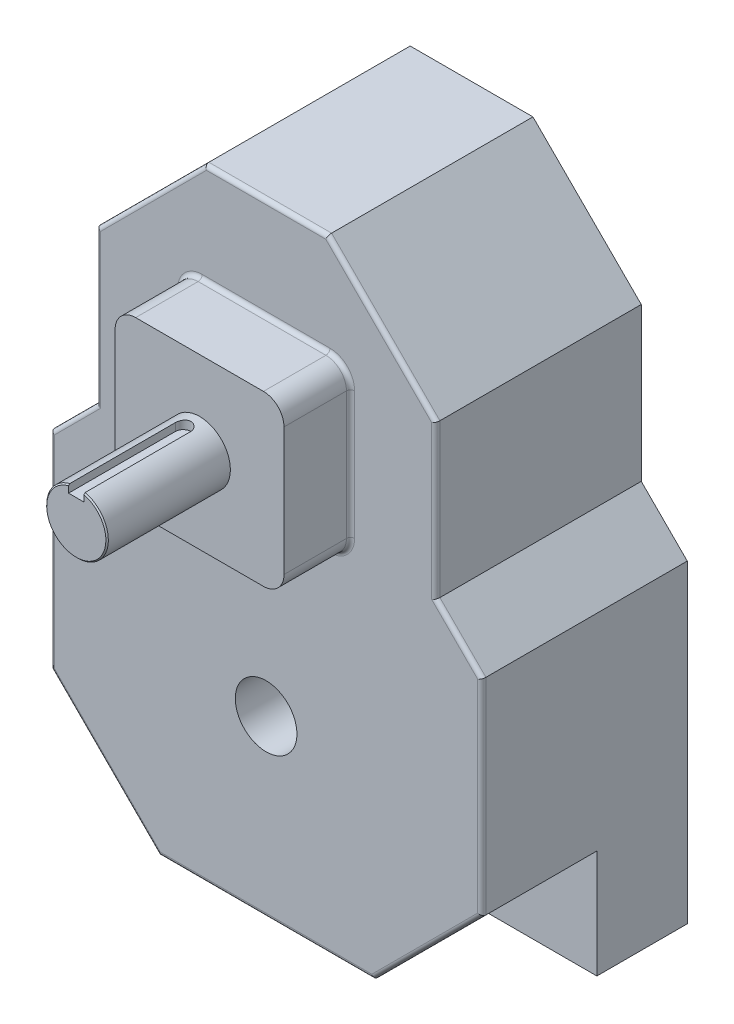
from build123d import *

# Parameters (mm, degrees)
BOSS_EXTRUDE1_DEPTH = 63.5
SKETCH3_W           = 52.197
SKETCH3_H           = 52.197
BOSS_EXTRUDE2_DEPTH = 20.574
SKETCH_D_R          = 9.525
BOSS_EXTRUDE3_DEPTH = 38.1
CUT_EXTRUDE1_DEPTH  = 35.56
FILLET1_R           = 6.35
FILLET2_R           = 1.27
KEYWAY_START        = 6.8326
KEYWAY_DEPTH        = 51.3174
CHAMFER1_SIZE       = 0.381
SKETCH7_R           = 9.525
CUT_EXTRUDE3_DEPTH  = 123.174


with BuildPart() as part:
    # L,M → Boss-Extrude1 (new body)
    with BuildSketch(Plane.XY):
        Polygon((-66.675, 53.975), (66.675, 53.975), (66.675, 151.07969491), (52.451, 165.30369491), (52.451, 212.64830509), (18.97330509, 246.126), (-18.97330509, 246.126), (-52.451, 212.64830509), (-52.451, 165.30369491), (-66.675, 151.07969491), align=None)
    extrude(amount=BOSS_EXTRUDE1_DEPTH)

    # Sketch3 → Boss-Extrude2 (add)
    with BuildSketch(Plane.XY.offset(63.5)):
        with Locations((0, 188.976)):
            Rectangle(SKETCH3_W, SKETCH3_H)
    extrude(amount=BOSS_EXTRUDE2_DEPTH)

    # D → Boss-Extrude3 (add)
    with BuildSketch(Plane.XY.offset(84.074)):
        with Locations((0, 188.976)):
            Circle(SKETCH_D_R)
    extrude(amount=BOSS_EXTRUDE3_DEPTH)

    # Sketch5 → Cut-Extrude1 (cut)
    with BuildSketch(Plane.XY.offset(63.5)):
        Polygon((66.675, 87.45269491), (33.19730509, 53.975), (66.675, 53.975), align=None)
        Polygon((-66.675, 53.975), (-66.675, 87.45269491), (-33.19730509, 53.975), align=None)
    extrude(amount=-CUT_EXTRUDE1_DEPTH, mode=Mode.SUBTRACT)

    # Fillet1
    fillet1_edges = [part.edges().sort_by_distance(p)[0] for p in [
        (-26.0985, 215.0745, 73.787),
        (-26.0985, 162.8775, 73.787),
        (26.0985, 162.8775, 73.787),
        (26.0985, 215.0745, 73.787),
    ]]
    fillet(fillet1_edges, radius=FILLET1_R)

    # Fillet2
    fillet2_edges = [part.edges().sort_by_distance(p)[0] for p in [
        (66.675, 119.26619491, 63.5),
        (49.936152545, 70.713847455, 63.5),
        (59.563, 158.19169491, 63.5),
        (52.451, 188.976, 63.5),
        (35.712152545, 229.387152545, 63.5),
        (0, 53.975, 63.5),
        (0, 246.126, 63.5),
        (-35.712152545, 229.387152545, 63.5),
        (-52.451, 188.976, 63.5),
        (-59.563, 158.19169491, 63.5),
        (-66.675, 119.26619491, 63.5),
        (-49.936152545, 70.713847455, 63.5),
        (0, 162.8775, 63.5),
        (-26.0985, 188.976, 63.5),
        (26.0985, 188.976, 63.5),
        (0, 215.0745, 63.5),
        (-24.238628061, 164.737371939, 63.5),
        (24.238628061, 164.737371939, 63.5),
        (-24.238628061, 213.214628061, 63.5),
        (24.238628061, 213.214628061, 63.5),
    ]]
    fillet(fillet2_edges, radius=FILLET2_R)

    # Sketch6 → Keyway (cut, through all)
    with BuildSketch(Plane(origin=(0, 188.976, 0), x_dir=(-1, 0, 0), z_dir=(0, 1, 0)).offset(KEYWAY_START)):
        with BuildLine():
            Line((2.3876, 122.174), (2.3876, 89.154))
            ThreePointArc((2.3876, 89.154), (0, 86.7664), (-2.3876, 89.154))
            Line((-2.3876, 89.154), (-2.3876, 122.174))
            ThreePointArc((-2.3876, 122.174), (0, 124.5616), (2.3876, 122.174))
        make_face()
    extrude(amount=KEYWAY_DEPTH, mode=Mode.SUBTRACT)

    # Chamfer1
    chamfer1_edges = [part.edges().sort_by_distance(p)[0] for p in [
        (-5.830254497, 181.443818543, 122.174),
    ]]
    chamfer(chamfer1_edges, length=CHAMFER1_SIZE)

    # Sketch7 → Cut-Extrude3 (cut, through all)
    with BuildSketch(Plane(origin=(0, 0, 0), x_dir=(-1, 0, 0), z_dir=(0, 0, -1))):
        with Locations((0, 107.95)):
            Circle(SKETCH7_R)
    extrude(amount=-CUT_EXTRUDE3_DEPTH, mode=Mode.SUBTRACT)


solid = part.part
